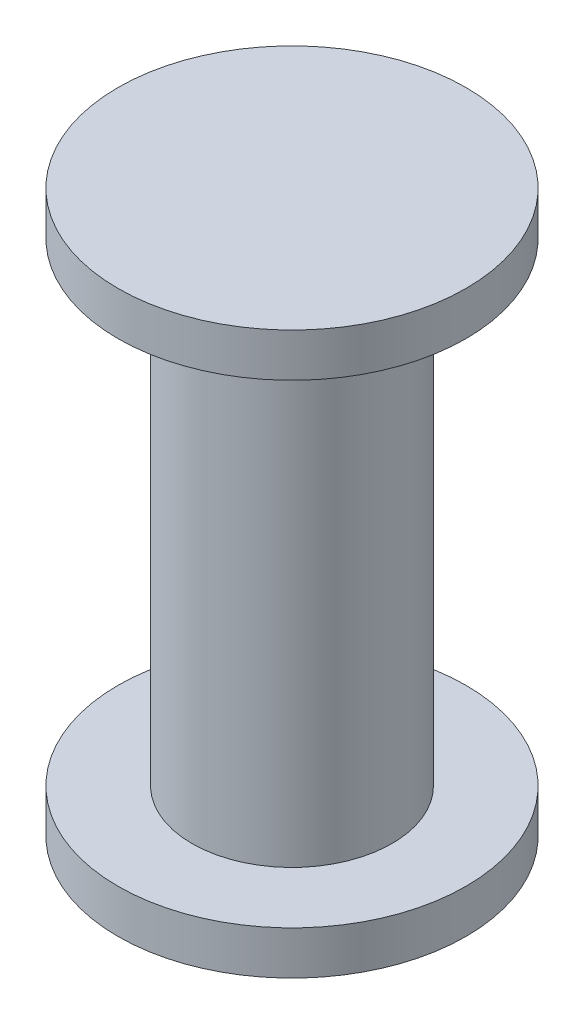
from build123d import *

# Parameters (mm, degrees)
SKETCH1_R           = 2.3
BOSS_EXTRUDE1_DEPTH = 12.9
BOSS_EXTRUDE2_START = 6.45
SKETCH2_R           = 4
SKETCH2_R_2         = 2.3
BOSS_EXTRUDE2_DEPTH = 1
BOSS_EXTRUDE3_START = -6.45
SKETCH2_3_R         = 4
SKETCH2_3_R_2       = 2.3
BOSS_EXTRUDE3_DEPTH = 1


with BuildPart() as part:
    # Sketch1 → Boss-Extrude1 (new body)
    with BuildSketch(Plane(origin=(0, 0, 0), x_dir=(1, 0, 0), z_dir=(0, 1, 0))):
        Circle(SKETCH1_R)
    extrude(amount=BOSS_EXTRUDE1_DEPTH)

    # Sketch2 → Boss-Extrude2 (add)
    with BuildSketch(Plane(origin=(0, 6.45, 0), x_dir=(1, 0, 0), z_dir=(0, 1, 0)).offset(BOSS_EXTRUDE2_START)):
        Circle(SKETCH2_R)
        Circle(SKETCH2_R_2, mode=Mode.SUBTRACT)
    extrude(amount=-BOSS_EXTRUDE2_DEPTH)

    # Sketch2_3 → Boss-Extrude3 (add)
    with BuildSketch(Plane(origin=(0, 6.45, 0), x_dir=(1, 0, 0), z_dir=(0, 1, 0)).offset(BOSS_EXTRUDE3_START)):
        Circle(SKETCH2_3_R)
        Circle(SKETCH2_3_R_2, mode=Mode.SUBTRACT)
    extrude(amount=BOSS_EXTRUDE3_DEPTH)


solid = part.part
